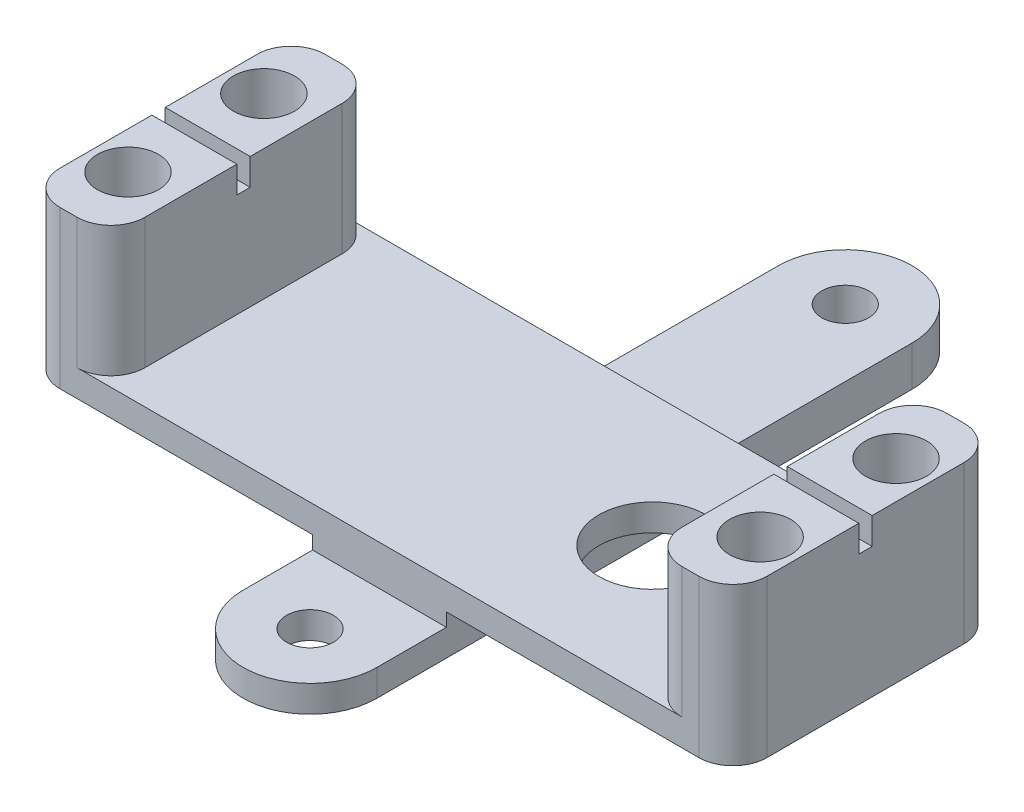
from build123d import *

# Parameters (mm, degrees)
BOSS_EXTRU_1_DEPTH      = 3
ENL_V_MAT_EXTRU_1_REACH = 5
ESQUISSE3_R             = 1.75
ESQUISSE4_W             = 52.83
ESQUISSE4_H             = 19.81
BOSS_EXTRU_2_DEPTH      = 2
ESQUISSE6_W             = 6.35
ESQUISSE6_H             = 19.81
BOSS_EXTRU_3_DEPTH      = 9.74
ENL_V_START             = -6
ESQUISSE5_R             = 2.286
ENL_V_MAT_EXTRU_2_DEPTH = 16.74
ESQUISSE7_R             = 4
ENL_V_MAT_EXTRU_3_DEPTH = 6
ESQUISSE8_W             = 1
ESQUISSE8_H             = 2
ENL_V_MAT_EXTRU_4_DEPTH = 53.83
ESQUISSE9_W             = 10.19
ESQUISSE9_H             = 1
ENL_V_MAT_EXTRU_5_DEPTH = 32.415
CONG_1_R                = 2.54
CONG_2_R                = 2.54


with BuildPart() as part:
    # Esquisse2 → Boss.-Extru.1 (new body)
    with BuildSketch(Plane(origin=(0, 0, 0), x_dir=(1, 0, 0), z_dir=(0, 1, 0))):
        with BuildLine():
            Line((-4.999130413, 19.906752432), (-4.999130413, -20.093247568))
            ThreePointArc((-4.999130413, -20.093247568), (0.046625811, -24.999782599), (5, -20))
            Line((5, -20), (5, 20))
            ThreePointArc((5, 20), (-0.046625811, 24.999782599), (-4.999130413, 19.906752432))
        make_face()
    extrude(amount=BOSS_EXTRU_1_DEPTH)

    # Esquisse3 → Enlèv. mat.-Extru.1 (cut, up to next)
    with BuildSketch(Plane(origin=(0, 3, 0), x_dir=(1, 0, 0), z_dir=(0, 1, 0)), mode=Mode.PRIVATE) as enl_v_mat_extru_1_sk1:
        with Locations((0, 20)):
            Circle(ESQUISSE3_R)
    enl_v_mat_extru_1_tool1 = extrude(enl_v_mat_extru_1_sk1.sketch, amount=-ENL_V_MAT_EXTRU_1_REACH, mode=Mode.PRIVATE) & part.part
    add(enl_v_mat_extru_1_tool1.solids().sort_by_distance((0, 3, -20))[0], mode=Mode.SUBTRACT)
    # Esquisse3 → Enlèv. mat.-Extru.1 (cut, up to next)
    with BuildSketch(Plane(origin=(0, 3, 0), x_dir=(1, 0, 0), z_dir=(0, 1, 0)), mode=Mode.PRIVATE) as enl_v_mat_extru_1_sk2:
        with Locations((0, -20)):
            Circle(ESQUISSE3_R)
    enl_v_mat_extru_1_tool2 = extrude(enl_v_mat_extru_1_sk2.sketch, amount=-ENL_V_MAT_EXTRU_1_REACH, mode=Mode.PRIVATE) & part.part
    add(enl_v_mat_extru_1_tool2.solids().sort_by_distance((0, 3, 20))[0], mode=Mode.SUBTRACT)

    # Esquisse4 → Boss.-Extru.2 (add)
    with BuildSketch(Plane(origin=(0, 3, 0), x_dir=(1, 0, 0), z_dir=(0, 1, 0))):
        with Locations((0, -4.905)):
            Rectangle(ESQUISSE4_W, ESQUISSE4_H)
    extrude(amount=BOSS_EXTRU_2_DEPTH)

    # Esquisse6 → Boss.-Extru.3 (add)
    with BuildSketch(Plane(origin=(0, 5, 0), x_dir=(1, 0, 0), z_dir=(0, 1, 0))):
        with Locations((-23.24, -4.905)):
            Rectangle(ESQUISSE6_W, ESQUISSE6_H)
    boss_extru_3 = extrude(amount=BOSS_EXTRU_3_DEPTH)

    # Esquisse5 → Enlèv. mat.-Extru.2 (cut)
    with BuildSketch(Plane(origin=(0, 5, 0), x_dir=(1, 0, 0), z_dir=(0, 1, 0)).offset(ENL_V_START)):
        with Locations((-23.621, 0.174)):
            Circle(ESQUISSE5_R)
        with Locations((-23.621, -9.984)):
            Circle(ESQUISSE5_R)
    enl_v_mat_extru_2 = extrude(amount=ENL_V_MAT_EXTRU_2_DEPTH, mode=Mode.SUBTRACT)

    # Symétrie1: Boss.-Extru.3, Enlèv. mat.-Extru.2 across plane
    add(boss_extru_3.mirror(Plane(origin=(0, 0, 0), x_dir=(0, 0, 1), z_dir=(1, 0, 0))))
    add(enl_v_mat_extru_2.mirror(Plane(origin=(0, 0, 0), x_dir=(0, 0, 1), z_dir=(1, 0, 0))), mode=Mode.SUBTRACT)

    # Esquisse7 → Enlèv. mat.-Extru.3 (cut, through all)
    with BuildSketch(Plane(origin=(0, 5, 0), x_dir=(1, 0, 0), z_dir=(0, 1, 0))):
        with Locations((10.415, -4.824151883)):
            Circle(ESQUISSE7_R)
    extrude(amount=-ENL_V_MAT_EXTRU_3_DEPTH, mode=Mode.SUBTRACT)

    # Esquisse8 → Enlèv. mat.-Extru.4 (cut, through all)
    with BuildSketch(Plane(origin=(26.415, 0, 0), x_dir=(0, 0, -1), z_dir=(1, 0, 0))):
        with Locations((-4.905, 13.74)):
            Rectangle(ESQUISSE8_W, ESQUISSE8_H)
    extrude(amount=-ENL_V_MAT_EXTRU_4_DEPTH, mode=Mode.SUBTRACT)

    # Esquisse9 → Enlèv. mat.-Extru.5 (cut, through all)
    with BuildSketch(Plane(origin=(5, 0, 0), x_dir=(0, 0, -1), z_dir=(1, 0, 0))):
        with Locations((-19.905, 2.5)):
            Rectangle(ESQUISSE9_W, ESQUISSE9_H)
    extrude(amount=-ENL_V_MAT_EXTRU_5_DEPTH, mode=Mode.SUBTRACT)

    # Congé1
    cong_1_edges = [part.edges().sort_by_distance(p)[0] for p in [
        (-26.415, 8.87, -5),
        (-26.415, 8.87, 14.81),
        (26.415, 8.87, 14.81),
        (26.415, 8.87, -5),
    ]]
    fillet(cong_1_edges, radius=CONG_1_R)

    # Congé2
    cong_2_edges = [part.edges().sort_by_distance(p)[0] for p in [
        (-20.065, 9.87, 14.81),
        (-20.065, 9.87, -5),
        (20.065, 9.87, -5),
        (20.065, 9.87, 14.81),
    ]]
    fillet(cong_2_edges, radius=CONG_2_R)


solid = part.part
